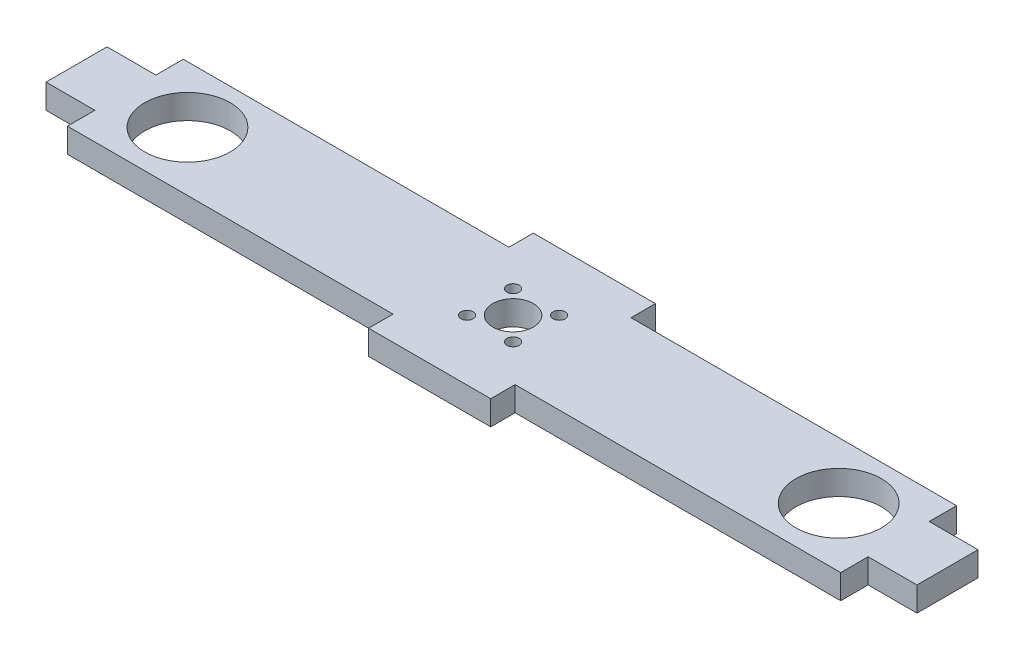
from build123d import *

# Parameters (mm, degrees)
SKETCH_1_R      = 10.5
SKETCH_1_R_2    = 5
SKETCH_1_R_3    = 1.5
EXTRUDE_1_DEPTH = 6


with BuildPart() as part:
    # Эскиз1 → Бобышка-Вытянуть1 (new body)
    with BuildSketch(Plane(origin=(0, 0, 0), x_dir=(1, 0, 0), z_dir=(0, 1, 0))):
        Polygon((-95, 14.235), (-15, 14.235), (-15, 20.235), (15, 20.235), (15, 14.235), (95, 14.235), (95, 7.5), (107, 7.5), (107, -7.5), (95, -7.5), (95, -14.235), (15, -14.235), (15, -20.235), (-15, -20.235), (-15, -14.235), (-95, -14.235), (-95, -7.5), (-107, -7.5), (-107, 7.5), (-95, 7.5), align=None)
        with Locations((-80, 0.265)):
            Circle(SKETCH_1_R, mode=Mode.SUBTRACT)
        with Locations((80, 0.265)):
            Circle(SKETCH_1_R, mode=Mode.SUBTRACT)
        with Locations((0, 0.265)):
            Circle(SKETCH_1_R_2, mode=Mode.SUBTRACT)
        with Locations((-5.656854249, 5.921854249)):
            Circle(SKETCH_1_R_3, mode=Mode.SUBTRACT)
        with Locations((5.656854249, 5.921854249)):
            Circle(SKETCH_1_R_3, mode=Mode.SUBTRACT)
        with Locations((5.656854249, -5.391854249)):
            Circle(SKETCH_1_R_3, mode=Mode.SUBTRACT)
        with Locations((-5.656854249, -5.391854249)):
            Circle(SKETCH_1_R_3, mode=Mode.SUBTRACT)
    extrude(amount=EXTRUDE_1_DEPTH)


solid = part.part
